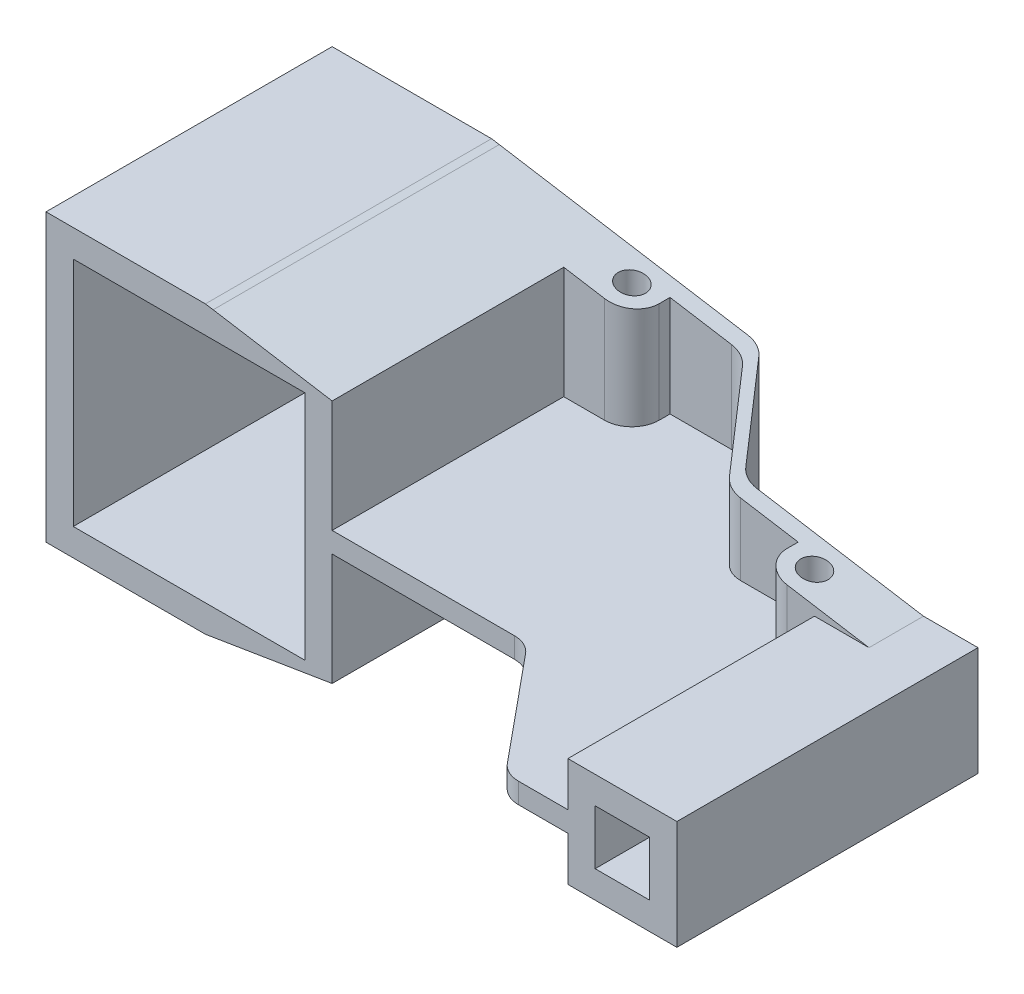
from build123d import *

# Parameters (mm, degrees)
ESQUISSE1_W             = 85
ESQUISSE1_H             = 85
BOSS_EXTRU_1_DEPTH      = 105
ESQUISSE2_W             = 25
ESQUISSE2_H             = 20
BOSS_EXTRU_2_DEPTH      = 105
ESQUISSE3_R             = 5
ENL_V_MAT_EXTRU_1_DEPTH = 106
BOSS_EXTRU_3_REACH      = 107
ESQUISSE5_W             = 25
ESQUISSE5_H             = 7.5
CONG_1_R                = 10
ESQUISSE6_W             = 40
ESQUISSE6_H             = 40
ESQUISSE6_W_2           = 20
ESQUISSE6_H_2           = 20.000133682
BOSS_EXTRU_5_DEPTH      = 83
BOSS_EXTRU_5_DEPTH_BACK = 176
ESQUISSE7_W             = 67.482972399
ESQUISSE7_H             = 90.273524416
ESQUISSE7_H_2           = 40
ENL_V_MAT_EXTRU_2_DEPTH = 106
ESQUISSE8_W             = 40
ESQUISSE8_H             = 25.5
ENL_V_MAT_EXTRU_3_DEPTH = 73.5
ESQUISSE9_W             = 20
ESQUISSE9_H             = 20
BOSS_EXTRU_7_DEPTH      = 40
ESQUISSE11_W            = 40.341877054
ESQUISSE11_H            = 20
BOSS_EXTRU_8_DEPTH      = 32.5
ESQUISSE12_W            = 40
ESQUISSE12_H            = 20
BOSS_EXTRU_9_DEPTH      = 32.5
ESQUISSE13_R            = 5
ENL_V_MAT_EXTRU_4_DEPTH = 106
BOSS_EXTRU_11_DEPTH     = 105
BOSS_EXTRU_12_REACH     = 152.5
ESQUISSE15_W            = 107.018090517
ESQUISSE15_H            = 7.5
CONG_2_R                = 10
CONG_3_R                = 10
ENL_V_MAT_EXTRU_6_DEPTH = 57.25
CONG_4_R                = 10
ENL_V_MAT_EXTRU_7_DEPTH = 151.5
ENL_V_MAT_EXTRU_8_DEPTH = 151.5
ENL_V_MAT_EXTRU_9_DEPTH = 151.5


with BuildPart() as part:
    # Esquisse1 → Boss.-Extru.1 (new body)
    with BuildSketch(Plane.XY):
        Polygon((-48.567045776, 45.091911765), (-95.067045776, 52.5), (-153.567045776, 52.5), (-153.567045776, -52.5), (-95.067045776, -52.5), (-48.567045776, -45.091911765), align=None)
        with Locations((-101.067045776, 0)):
            Rectangle(ESQUISSE1_W, ESQUISSE1_H, mode=Mode.SUBTRACT)
    extrude(amount=BOSS_EXTRU_1_DEPTH)

    # Esquisse2 → Boss.-Extru.2 (add, through all)
    with BuildSketch(Plane.XZ.offset(52.5)):
        with Locations((-36.067045776, 10)):
            Rectangle(ESQUISSE2_W, ESQUISSE2_H)
    extrude(amount=-BOSS_EXTRU_2_DEPTH)

    # Esquisse3 → Enlèv. mat.-Extru.1 (cut, through all)
    with BuildSketch(Plane.XZ.offset(52.5)):
        with Locations((-33.567045776, 10)):
            Circle(ESQUISSE3_R)
    extrude(amount=-ENL_V_MAT_EXTRU_1_DEPTH, mode=Mode.SUBTRACT)

    # Esquisse5 → Boss.-Extru.3 (add, up to next)
    with BuildSketch(Plane.XY.offset(105), mode=Mode.PRIVATE) as boss_extru_3_sk1:
        with Locations((-36.067045776, 0)):
            Rectangle(ESQUISSE5_W, ESQUISSE5_H)
    boss_extru_3_tool1 = extrude(boss_extru_3_sk1.sketch, amount=-BOSS_EXTRU_3_REACH, mode=Mode.PRIVATE) - part.part
    add(boss_extru_3_tool1.solids().sort_by_distance((-36.067046, 0, 105))[0])

    # Congé1
    cong_1_edges = [part.edges().sort_by_distance(p)[0] for p in [
        (-23.567045776, 28.125, 20),
        (-23.567045776, -28.125, 20),
    ]]
    fillet(cong_1_edges, radius=CONG_1_R)



with BuildPart() as body_2:
    # Esquisse6 → Boss.-Extru.5 (new body, two sides)
    with BuildSketch(Plane(origin=(0, 0, 0), x_dir=(-1, 0, 0), z_dir=(0, 0, -1))) as boss_extru_5_sk:
        with Locations((-103.451044741, 0)):
            Rectangle(ESQUISSE6_W, ESQUISSE6_H)
        with Locations((-103.451044741, 0)):
            Rectangle(ESQUISSE6_W_2, ESQUISSE6_H_2, mode=Mode.SUBTRACT)
    extrude(amount=BOSS_EXTRU_5_DEPTH)
    extrude(boss_extru_5_sk.sketch, amount=-BOSS_EXTRU_5_DEPTH_BACK)

    # Esquisse7 → Enlèv. mat.-Extru.2 (cut, through all)
    with BuildSketch(Plane.XZ.offset(52.5)):
        with Locations((109.464150934, -45.136762208)):
            Rectangle(ESQUISSE7_W, ESQUISSE7_H)
        with Locations((109.464150934, 20)):
            Rectangle(ESQUISSE7_W, ESQUISSE7_H_2)
    extrude(amount=-ENL_V_MAT_EXTRU_2_DEPTH, mode=Mode.SUBTRACT)

    # Esquisse8 → Enlèv. mat.-Extru.3 (cut, through all)
    with BuildSketch(Plane.XZ.offset(20)):
        with Locations((103.451044741, 163.25)):
            Rectangle(ESQUISSE8_W, ESQUISSE8_H)
    extrude(amount=-ENL_V_MAT_EXTRU_3_DEPTH, mode=Mode.SUBTRACT)

    # Esquisse9 → Boss.-Extru.7 (add)
    with BuildSketch(Plane(origin=(0, -20, 0), x_dir=(-1, 0, 0), z_dir=(0, -1, 0))):
        with Locations((-73.451044741, -50)):
            Rectangle(ESQUISSE9_W, ESQUISSE9_H)
    extrude(amount=-BOSS_EXTRU_7_DEPTH)

    # Esquisse11 → Boss.-Extru.8 (add)
    with BuildSketch(Plane.XZ.offset(52.5)):
        with Locations((83.621983268, 50)):
            Rectangle(ESQUISSE11_W, ESQUISSE11_H)
    extrude(amount=-BOSS_EXTRU_8_DEPTH)

    # Esquisse12 → Boss.-Extru.9 (add)
    with BuildSketch(Plane(origin=(0, 52.5, 0), x_dir=(1, 0, 0), z_dir=(0, 1, 0))):
        with Locations((83.451044741, -50)):
            Rectangle(ESQUISSE12_W, ESQUISSE12_H)
    extrude(amount=-BOSS_EXTRU_9_DEPTH)

    # Esquisse13 → Enlèv. mat.-Extru.4 (cut, through all)
    with BuildSketch(Plane.XZ.offset(52.5)):
        with Locations((73.451044741, 50)):
            Circle(ESQUISSE13_R)
    extrude(amount=-ENL_V_MAT_EXTRU_4_DEPTH, mode=Mode.SUBTRACT)


with BuildPart() as part_1:
    add(part.part)

    add(body_2.part)  # Boss.-Extru.11 merges body 2
    # Esquisse14 → Boss.-Extru.11 (add, through all)
    with BuildSketch(Plane.XZ.offset(52.5)):
        with BuildLine():
            Line((-23.567045776, 0), (-1.074115191, 0))
            ThreePointArc((-1.074115191, 0), (3.110427636, 0.917621383), (6.527005267, 3.502079733))
            Line((6.527005267, 3.502079733), (34.733944249, 36.497920267))
            ThreePointArc((34.733944249, 36.497920267), (38.15052188, 39.082378617), (42.335064706, 40))
            Line((42.335064706, 40), (63.451044741, 40))
            Line((63.451044741, 40), (63.451044741, 46))
            Line((63.451044741, 46), (42.335064706, 46))
            ThreePointArc((42.335064706, 46), (38.15052188, 45.082378617), (34.733944249, 42.497920267))
            Line((34.733944249, 42.497920267), (6.527005267, 9.502079733))
            ThreePointArc((6.527005267, 9.502079733), (3.110427636, 6.917621383), (-1.074115191, 6))
            Line((-1.074115191, 6), (-23.567045776, 6))
            Line((-23.567045776, 6), (-23.567045776, 0))
        make_face()
    extrude(amount=-BOSS_EXTRU_11_DEPTH)

    # Esquisse15 → Boss.-Extru.12 (add, up to next)
    with BuildSketch(Plane.XY.offset(150.5), mode=Mode.PRIVATE) as boss_extru_12_sk1:
        with Locations((29.941999483, 0)):
            Rectangle(ESQUISSE15_W, ESQUISSE15_H)
    boss_extru_12_tool1 = extrude(boss_extru_12_sk1.sketch, amount=-BOSS_EXTRU_12_REACH, mode=Mode.PRIVATE) - part_1.part
    add(boss_extru_12_tool1.solids().sort_by_distance((29.941999, 0, 150.5))[0])

    # Congé2
    cong_2_edges = [part_1.edges().sort_by_distance(p)[0] for p in [
        (63.451044741, -28.125, 60),
    ]]
    fillet(cong_2_edges, radius=CONG_2_R)

    # Congé3
    cong_3_edges = [part_1.edges().sort_by_distance(p)[0] for p in [
        (63.451044741, 28.125, 60),
    ]]
    fillet(cong_3_edges, radius=CONG_3_R)

    # Esquisse16 → Enlèv. mat.-Extru.6 (cut, through all)
    with BuildSketch(Plane.XZ.offset(3.75)):
        with BuildLine():
            Line((60.598915971, 150.5), (26.069543092, 108.637003713))
            ThreePointArc((26.069543092, 108.637003713), (22.619512531, 105.954836572), (18.355122942, 105))
            Line((18.355122942, 105), (-23.567045776, 105))
            Line((-23.567045776, 105), (-23.567045776, 150.5))
            Line((-23.567045776, 150.5), (60.598915971, 150.5))
        make_face()
    extrude(amount=-ENL_V_MAT_EXTRU_6_DEPTH, mode=Mode.SUBTRACT)

    # Congé4
    cong_4_edges = [part_1.edges().sort_by_distance(p)[0] for p in [
        (60.598915971, 0, 150.5),
    ]]
    fillet(cong_4_edges, radius=CONG_4_R)

    # Esquisse17 → Enlèv. mat.-Extru.7 (cut, through all)
    with BuildSketch(Plane.XY.offset(150.5)):
        Polygon((-93.466358172, -52.244988494), (103.792921795, -20), (103.792921795, -55.275638449), align=None)
    extrude(amount=-ENL_V_MAT_EXTRU_7_DEPTH, mode=Mode.SUBTRACT)

    # Esquisse18 → Enlèv. mat.-Extru.8 (cut, through all)
    with BuildSketch(Plane.XY.offset(150.5)):
        Polygon((-92.222865715, 52.046883079), (103.451044741, 20), (103.451044741, 52.5), align=None)
    extrude(amount=-ENL_V_MAT_EXTRU_8_DEPTH, mode=Mode.SUBTRACT)

    # Esquisse19 → Enlèv. mat.-Extru.9 (cut, through all)
    with BuildSketch(Plane.XY.offset(150.5)):
        Polygon((-79.463248921, 79.178617238), (139.979375794, 56.935567532), (111.241114329, 33.487041007), (-48.920553802, 47.63996467), align=None)
    extrude(amount=-ENL_V_MAT_EXTRU_9_DEPTH, mode=Mode.SUBTRACT)


solid = part_1.part
